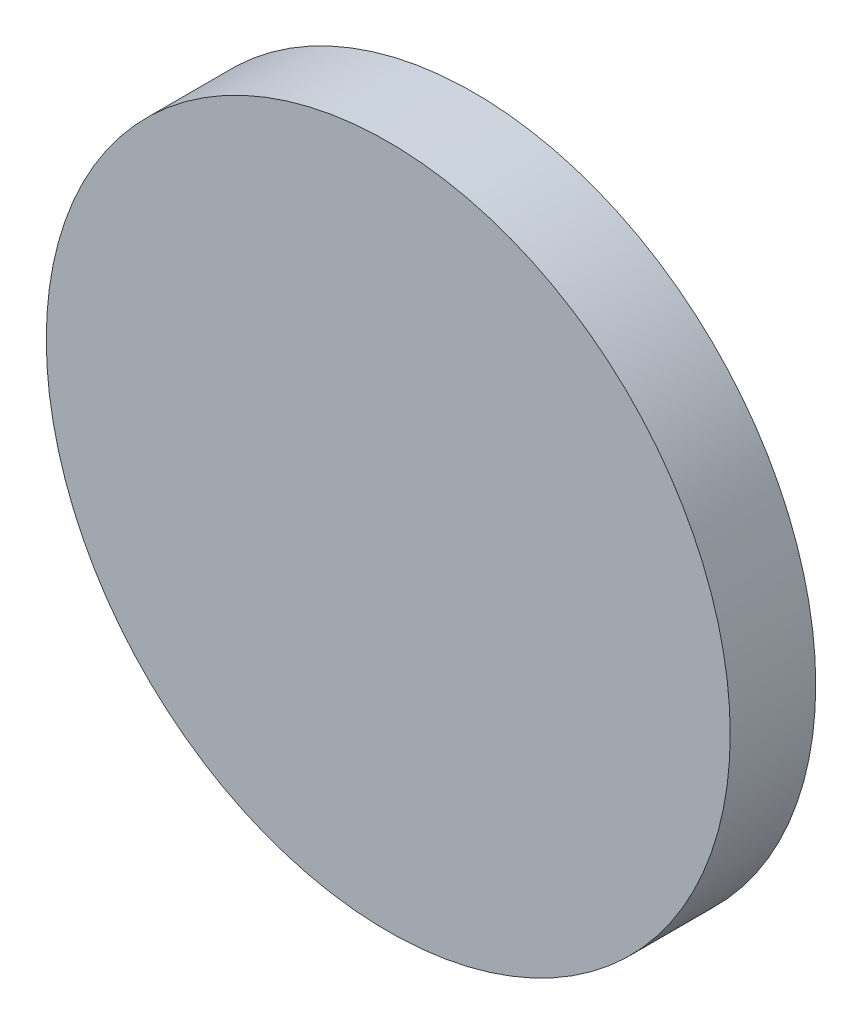
from build123d import *

# Parameters (mm, degrees)
SKETCH1_R           = 4
BOSS_EXTRUDE1_DEPTH = 1


with BuildPart() as part:
    # Sketch1 → Boss-Extrude1 (new body)
    with BuildSketch(Plane.XY):
        Circle(SKETCH1_R)
    extrude(amount=BOSS_EXTRUDE1_DEPTH)


solid = part.part
